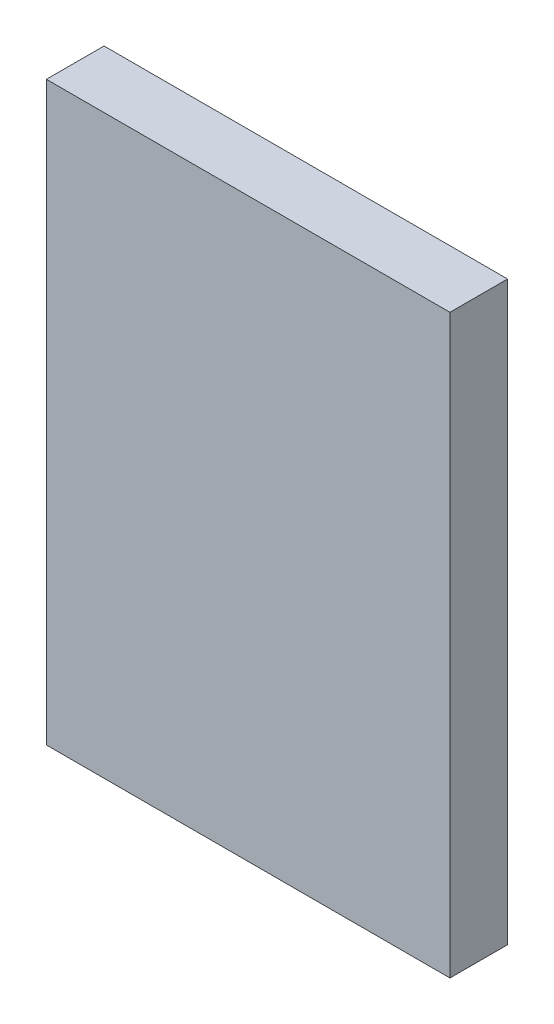
from build123d import *

# Parameters (mm, degrees)
SKETCH1_W           = 700
SKETCH1_H           = 1000
BOSS_EXTRUDE1_DEPTH = 50


with BuildPart() as part:
    # Sketch1 → Boss-Extrude1 (new body, symmetric)
    with BuildSketch(Plane.XY):
        Rectangle(SKETCH1_W, SKETCH1_H)
    extrude(amount=BOSS_EXTRUDE1_DEPTH, both=True)


solid = part.part
